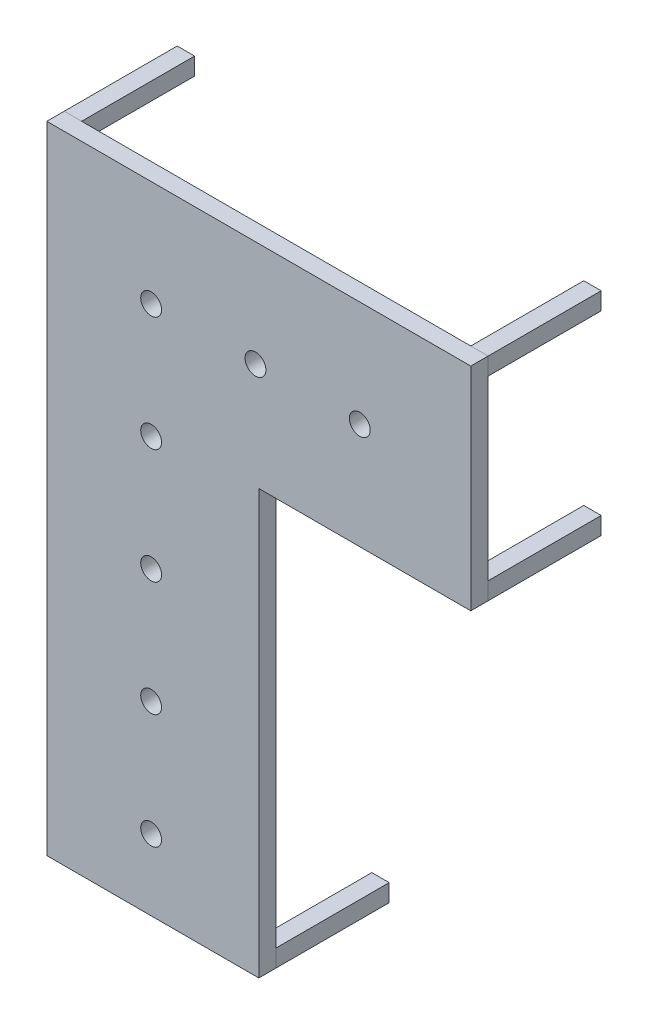
from build123d import *

# Parameters (mm, degrees)
BOSS_EXTRUDE1_DEPTH   = 100
SKETCH4_W             = 100
SKETCH4_H             = 100
BOSS_EXTRUDE2_DEPTH   = 650
BOSS_EXTRUDE2_2_DEPTH = 650
BOSS_EXTRUDE2_3_DEPTH = 650
BOSS_EXTRUDE2_4_DEPTH = 650
BOSS_EXTRUDE2_5_DEPTH = 650
BOSS_EXTRUDE2_6_DEPTH = 650
BOSS_EXTRUDE2_7_DEPTH = 650
SKETCH5_R             = 60
CUT_EXTRUDE2_DEPTH    = 101


with BuildPart() as part:
    # Sketch3 → Boss-Extrude1 (new body)
    with BuildSketch(Plane.XY):
        Polygon((2438.4, -1219.2), (2438.4, 0), (0, 0), (0, -3657.6), (1219.2, -3657.6), (1219.2, -1219.2), align=None)
    extrude(amount=BOSS_EXTRUDE1_DEPTH)

    # Sketch5 → Cut-Extrude2 (cut, through all)
    with BuildSketch(Plane(origin=(0, 0, 0), x_dir=(-1, 0, 0), z_dir=(0, 0, -1))):
        with Locations((-600, -3249.2)):
            Circle(SKETCH5_R)
        with Locations((-600, -2589.2)):
            Circle(SKETCH5_R)
        with Locations((-600, -1929.2)):
            Circle(SKETCH5_R)
        with Locations((-600, -1269.2)):
            Circle(SKETCH5_R)
        with Locations((-600, -609.2)):
            Circle(SKETCH5_R)
        with Locations((-1200, -609.2)):
            Circle(SKETCH5_R)
        with Locations((-1800, -609.2)):
            Circle(SKETCH5_R)
    extrude(amount=-CUT_EXTRUDE2_DEPTH, mode=Mode.SUBTRACT)


with BuildPart() as body_2:
    # Sketch4 → Boss-Extrude2 (new body)
    with BuildSketch(Plane(origin=(0, 0, 0), x_dir=(-1, 0, 0), z_dir=(0, 0, -1))):
        with Locations((-2388.4, -50)):
            Rectangle(SKETCH4_W, SKETCH4_H)
    extrude(amount=BOSS_EXTRUDE2_DEPTH)


with BuildPart() as body_3:
    # Sketch4 → Boss-Extrude2 2 (new body)
    with BuildSketch(Plane(origin=(0, 0, 0), x_dir=(-1, 0, 0), z_dir=(0, 0, -1))):
        with Locations((-50, -3607.6)):
            Rectangle(SKETCH4_W, SKETCH4_H)
    extrude(amount=BOSS_EXTRUDE2_2_DEPTH)


with BuildPart() as body_4:
    # Sketch4 → Boss-Extrude2 3 (new body)
    with BuildSketch(Plane(origin=(0, 0, 0), x_dir=(-1, 0, 0), z_dir=(0, 0, -1))):
        with Locations((-50, -50)):
            Rectangle(SKETCH4_W, SKETCH4_H)
    extrude(amount=BOSS_EXTRUDE2_3_DEPTH)


with BuildPart() as body_5:
    # Sketch4 → Boss-Extrude2 4 (new body)
    with BuildSketch(Plane(origin=(0, 0, 0), x_dir=(-1, 0, 0), z_dir=(0, 0, -1))):
        with Locations((-1169.2, -3607.6)):
            Rectangle(SKETCH4_W, SKETCH4_H)
    extrude(amount=BOSS_EXTRUDE2_4_DEPTH)


with BuildPart() as body_6:
    # Sketch4 → Boss-Extrude2 5 (new body)
    with BuildSketch(Plane(origin=(0, 0, 0), x_dir=(-1, 0, 0), z_dir=(0, 0, -1))):
        with Locations((-1169.2, -1169.2)):
            Rectangle(SKETCH4_W, SKETCH4_H)
    extrude(amount=BOSS_EXTRUDE2_5_DEPTH)


with BuildPart() as body_7:
    # Sketch4 → Boss-Extrude2 6 (new body)
    with BuildSketch(Plane(origin=(0, 0, 0), x_dir=(-1, 0, 0), z_dir=(0, 0, -1))):
        with Locations((-2388.4, -1169.2)):
            Rectangle(SKETCH4_W, SKETCH4_H)
    extrude(amount=BOSS_EXTRUDE2_6_DEPTH)


with BuildPart() as body_8:
    # Sketch4 → Boss-Extrude2 7 (new body)
    with BuildSketch(Plane(origin=(0, 0, 0), x_dir=(-1, 0, 0), z_dir=(0, 0, -1))):
        with Locations((-50, -1169.2)):
            Rectangle(SKETCH4_W, SKETCH4_H)
    extrude(amount=BOSS_EXTRUDE2_7_DEPTH)


solid = Compound([part.part, body_2.part, body_3.part, body_4.part, body_5.part, body_6.part, body_7.part, body_8.part])
